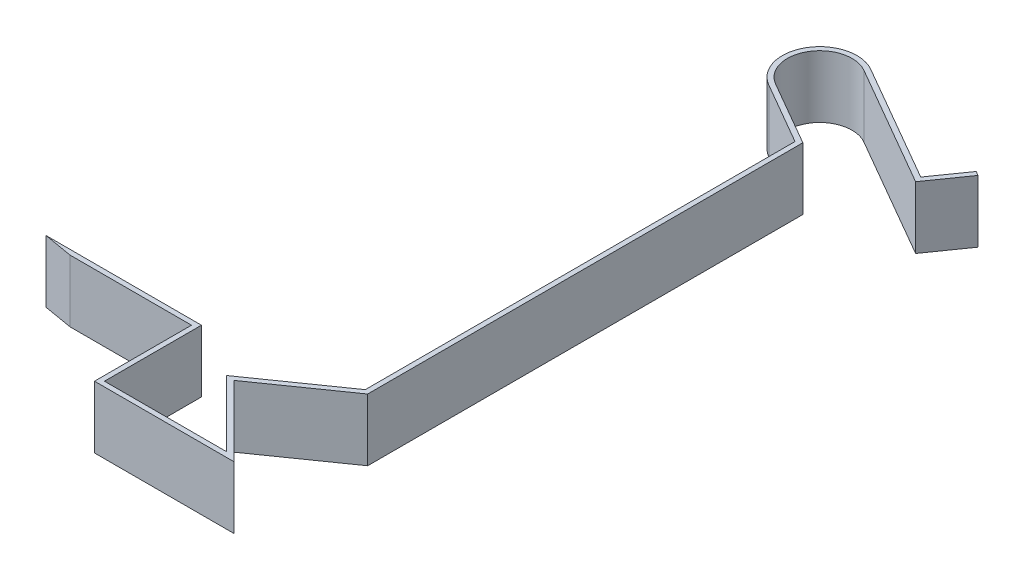
from build123d import *

# Parameters (mm, degrees)
EXTRUDE_1_DEPTH = 2.5


with BuildPart() as part:
    # 草图1 → 凸台-拉伸1 (new body)
    with BuildSketch(Plane(origin=(0, 0, 0), x_dir=(1, 0, 0), z_dir=(0, 1, 0))):
        with BuildLine():
            Line((-10.934737319, 12.934852592), (-4.684737319, 12.934852592))
            Line((-4.684737319, 12.934852592), (-4.684737319, 9.034852592))
            Line((-4.684737319, 9.034852592), (0.232419968, 9.034852592))
            Line((0.232419968, 9.034852592), (-2.42312521, 11.69039777))
            Line((-2.42312521, 11.69039777), (0.853482967, 13.984703515))
            Line((0.853482967, 13.984703515), (0.853482967, 31.265120051))
            Line((0.853482967, 31.265120051), (-1.644593244, 32.707385024))
            ThreePointArc((-1.644593244, 32.707385024), (-2.19363135, 34.75642313), (-0.144593244, 35.305461236))
            Line((-0.144593244, 35.305461236), (4.618546477, 32.555461236))
            Line((4.618546477, 32.555461236), (5.538541961, 33.864509863))
            Line((5.538541961, 33.864509863), (5.712435322, 33.764112484))
            Line((5.712435322, 33.764112484), (4.676983419, 32.290782544))
            Line((4.676983419, 32.290782544), (-0.244593244, 35.132256155))
            ThreePointArc((-0.244593244, 35.132256155), (-2.020426269, 34.65642313), (-1.544593244, 32.880590105))
            Line((-1.544593244, 32.880590105), (1.053482967, 31.380590105))
            Line((1.053482967, 31.380590105), (1.053482967, 13.880590105))
            Line((1.053482967, 13.880590105), (-2.113164444, 11.663279717))
            Line((-2.113164444, 11.663279717), (0.715262681, 8.834852592))
            Line((0.715262681, 8.834852592), (-4.884737319, 8.834852592))
            Line((-4.884737319, 8.834852592), (-4.884737319, 12.734852592))
            Line((-4.884737319, 12.734852592), (-9.767685017, 12.734852592))
            Line((-9.767685017, 12.734852592), (-10.934737319, 12.934852592))
        make_face()
    extrude(amount=EXTRUDE_1_DEPTH)


solid = part.part
